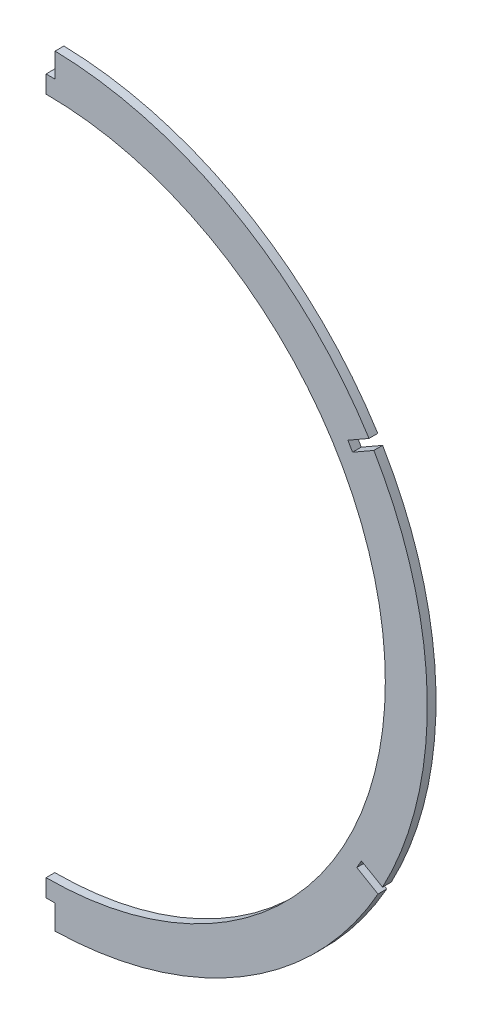
from build123d import *

# Parameters (mm, degrees)
BOSS_EXTRUDE1_DEPTH = 1.5875
CUT_EXTRUDE1_DEPTH  = 3.175
FILLET1_R           = 8.89
SKETCH4_W           = 218.524279389
SKETCH4_H           = 440.65456999
CUT_EXTRUDE3_DEPTH  = 139.43
CUT_EXTRUDE4_DEPTH  = 4.175


with BuildPart() as part:
    # Sketch1 → Boss-Extrude1 (new body, symmetric)
    with BuildSketch(Plane.XY):
        with BuildLine():
            Line((-127.293308919, -32.555250036), (-85.984130762, -73.864428193))
            Line((-85.984130762, -73.864428193), (-85.984130762, -86.643760402))
            ThreePointArc((-85.984130762, -86.643760402), (-70.818680903, -97.099597285), (-54.399250036, -105.449308919))
            ThreePointArc((-54.399250036, -105.449308919), (97.88479172, 119.72879172), (-127.293308919, -32.555250036))
        make_face()
    extrude(amount=BOSS_EXTRUDE1_DEPTH, both=True)

    # Sketch2 → Cut-Extrude1 (cut)
    with BuildSketch(Plane.XY.offset(1.5875)):
        with BuildLine():
            Line((-114.372852664, -23.923091601), (-70.744130762, -67.551813503))
            Line((-70.744130762, -67.551813503), (-70.744130762, -79.00759425))
            ThreePointArc((-70.744130762, -79.00759425), (96.569405073, 98.330117066), (-114.372852664, -23.923091601))
        make_face()
    extrude(amount=-CUT_EXTRUDE1_DEPTH, mode=Mode.SUBTRACT)

    # Fillet1
    fillet1_edges = [part.edges().sort_by_distance(p)[0] for p in [
        (-114.372852664, -23.923091601, 0),
        (-70.744130762, -79.00759425, 0),
        (-70.744130762, -67.551813503, 0),
        (-85.984130762, -86.643760402, -0.79375),
        (-85.984130762, -73.864428193, -0.79375),
        (-127.293308919, -32.555250036, -0.79375),
    ]]
    fillet(fillet1_edges, radius=FILLET1_R)

    # Sketch4 → Cut-Extrude3 (cut, through all)
    with BuildSketch(Plane(origin=(0, 0, 0), x_dir=(0, 0, -1), z_dir=(1, 0, 0))):
        with Locations((12.98164036, 12.468370851)):
            Rectangle(SKETCH4_W, SKETCH4_H)
    extrude(amount=-CUT_EXTRUDE3_DEPTH, mode=Mode.SUBTRACT)

    # Sketch5 → Cut-Extrude4 (cut, through all)
    with BuildSketch(Plane(origin=(0, 0, -1.5875), x_dir=(-1, 0, 0), z_dir=(0, 0, -1))):
        with BuildLine():
            Line((-114.517752975, -38.815428837), (-122.170481647, -43.250072804))
            ThreePointArc((-122.170481647, -43.250072804), (-121.36689626, -44.736337881), (-120.545230584, -46.212684341))
            Line((-120.545230584, -46.212684341), (-112.823974718, -41.738329871))
            Line((-112.823974718, -41.738329871), (-114.517752975, -38.815428837))
        make_face()
        with BuildLine():
            Line((-109.598496198, 91.009030044), (-117.267867629, 95.404261839))
            ThreePointArc((-117.267867629, 95.404261839), (-118.157043978, 93.967351685), (-119.028614444, 92.519694857))
            Line((-119.028614444, 92.519694857), (-111.278220029, 88.078029687))
            Line((-111.278220029, 88.078029687), (-109.598496198, 91.009030044))
        make_face()
        with BuildLine():
            Line((-3.302, 160.234612745), (-3.302, 151.384))
            Line((-3.302, 151.384), (0, 151.384))
            Line((0, 151.384), (0, 160.274))
            ThreePointArc((0, 160.274), (-1.651117452, 160.264152836), (-3.302, 160.234612745))
        make_face()
        with BuildLine():
            Line((-3.302, -107.696), (-3.302, -116.546612745))
            ThreePointArc((-3.302, -116.546612745), (-1.651117452, -116.576152836), (0, -116.586))
            Line((0, -116.586), (0, -107.696))
            Line((0, -107.696), (-3.302, -107.696))
        make_face()
    extrude(amount=-CUT_EXTRUDE4_DEPTH, mode=Mode.SUBTRACT)


solid = part.part
